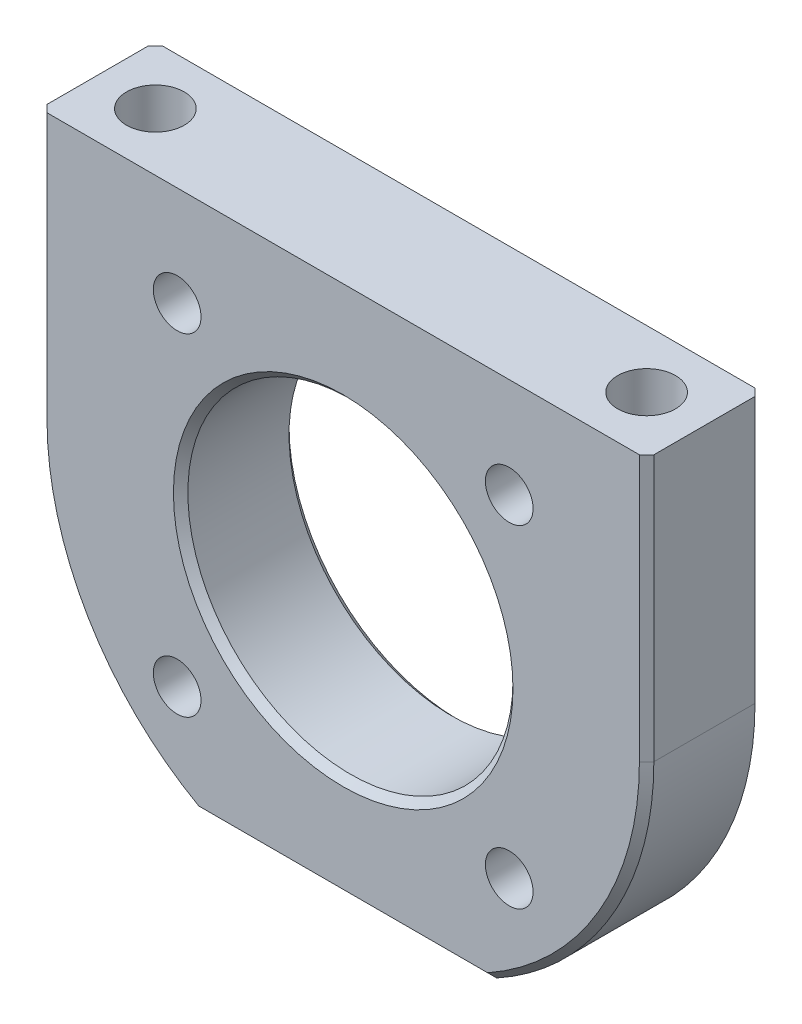
from build123d import *

# Parameters (mm, degrees)
BOSS_EXTRUDE1_DEPTH       = 4
SKETCH2_R                 = 11.25
CUT_EXTRUDE1_DEPTH        = 9
M4X0_7_TAPPED_HOLE3_D     = 3.3
M4X0_7_TAPPED_HOLE1_D     = 3.3
M4X0_7_TAPPED_HOLE1_DEPTH = 8
M4X0_7_TAPPED_HOLE1_TIP   = 0.991420021
SKETCH6_R                 = 2
CUT_EXTRUDE3_DEPTH        = 8
CHAMFER1_SIZE             = 0.5


with BuildPart() as part:
    # Sketch1 → Boss-Extrude1 (new body, symmetric)
    with BuildSketch(Plane.XY):
        with BuildLine():
            Line((21, 0), (21, 18.4))
            Line((21, 18.4), (-21, 18.4))
            Line((-21, 18.4), (-21, 0))
            ThreePointArc((-21, 0), (-18.076871405, -10.687690125), (-10.121264743, -18.4))
            Line((-10.121264743, -18.4), (10.121264743, -18.4))
            ThreePointArc((10.121264743, -18.4), (18.076871405, -10.687690125), (21, 0))
        make_face()
    extrude(amount=BOSS_EXTRUDE1_DEPTH, both=True)

    # Sketch2 → Cut-Extrude1 (cut, through all)
    with BuildSketch(Plane.XY.offset(4)):
        Circle(SKETCH2_R)
    extrude(amount=-CUT_EXTRUDE1_DEPTH, mode=Mode.SUBTRACT)

    # M4x0.7 Tapped Hole3 (through all)
    with Locations(Plane.XY.offset(4)):
        with Locations((-11.490485194, 11.490485194), (11.490485194, 11.490485194), (11.490485194, -11.490485194), (-11.490485194, -11.490485194)):
            Hole(M4X0_7_TAPPED_HOLE3_D / 2)

    # M4x0.7 Tapped Hole1
    with Locations(Plane(origin=(0, 18.4, 0), x_dir=(1, 0, 0), z_dir=(0, 1, 0))):
        with Locations((-17, 0), (17, 0)):
            Hole(M4X0_7_TAPPED_HOLE1_D / 2, depth=M4X0_7_TAPPED_HOLE1_DEPTH)
            with Locations((0, 0, -(M4X0_7_TAPPED_HOLE1_DEPTH + M4X0_7_TAPPED_HOLE1_TIP / 2))):  # 118° drill point
                Cone(0, M4X0_7_TAPPED_HOLE1_D / 2, M4X0_7_TAPPED_HOLE1_TIP, mode=Mode.SUBTRACT)

    # Sketch6 → Cut-Extrude3 (cut)
    with BuildSketch(Plane(origin=(-3.375, 18.4, 0), x_dir=(0, 0, -1), z_dir=(0, -1, 0))):
        with Locations((0, -13.625)):
            Circle(SKETCH6_R)
        with Locations((0, 20.375)):
            Circle(SKETCH6_R)
    extrude(amount=CUT_EXTRUDE3_DEPTH, mode=Mode.SUBTRACT)

    # Chamfer1
    chamfer1_edges = [part.edges().sort_by_distance(p)[0] for p in [
        (-21, 9.2, 4),
        (-18.076871405, -10.687690125, 4),
        (0, -18.4, 4),
        (-11.25, 0, -4),
        (-11.25, 0, 4),
        (18.076871405, -10.687690125, 4),
        (0, -18.4, -4),
        (-18.076871405, -10.687690125, -4),
        (-21, 9.2, -4),
        (21, 9.2, 4),
        (21, 9.2, -4),
        (18.076871405, -10.687690125, -4),
    ]]
    chamfer(chamfer1_edges, length=CHAMFER1_SIZE)


solid = part.part
